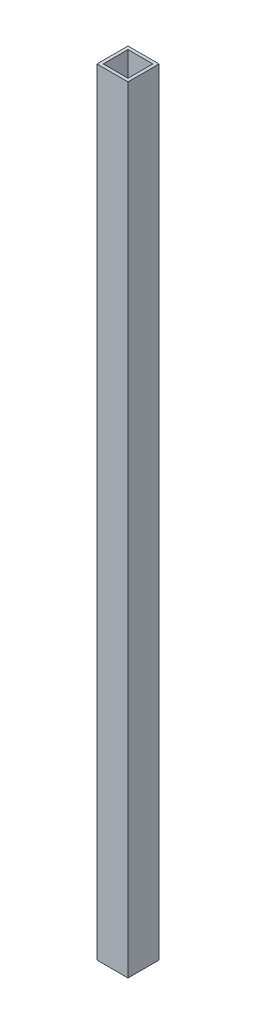
from build123d import *

# Parameters (mm, degrees)
SKETCH_1_W      = 10
SKETCH_1_H      = 10
SKETCH_1_W_2    = 8
SKETCH_1_H_2    = 8
EXTRUDE_1_DEPTH = 250


with BuildPart() as part:
    # Эскиз1 → Бобышка-Вытянуть1 (new body)
    with BuildSketch(Plane(origin=(0, 0, 0), x_dir=(1, 0, 0), z_dir=(0, 1, 0))):
        Rectangle(SKETCH_1_W, SKETCH_1_H)
        Rectangle(SKETCH_1_W_2, SKETCH_1_H_2, mode=Mode.SUBTRACT)
    extrude(amount=EXTRUDE_1_DEPTH)


solid = part.part
